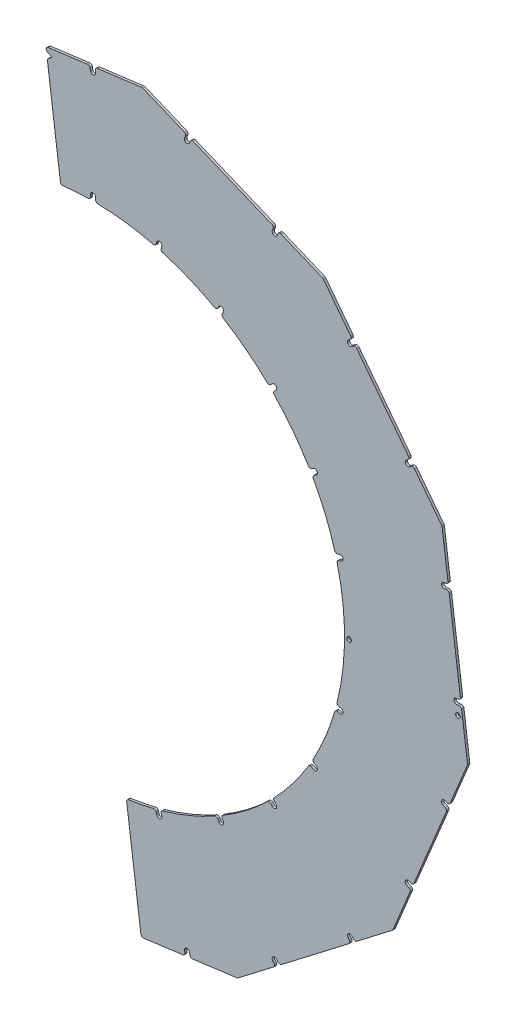
from build123d import *

# Parameters (mm, degrees)
BOSS_EXTRUDE1_DEPTH      = 2
CUT_EXTRUDE1_DEPTH       = 3
CUT_EXTRUDE2_DEPTH       = 3
CIRPATTERN1_COUNT        = 6
CIRPATTERN1_ANGLE        = 150
SKETCH4_R                = 2
BOSS_EXTRUDE3_DEPTH      = 2
FILLET1_R                = 2
F_4_0_4_DIAMETER_HOLE1_D = 4
ALIGNMENT_VEE_CUT_DEPTH  = 3


with BuildPart() as part:
    # Sketch1 → Boss-Extrude1 (new body)
    with BuildSketch(Plane.XY):
        with BuildLine():
            Line((-40.783185859, 313.609700506), (-27.95891263, 216.199674386))
            ThreePointArc((-27.95891263, 216.199674386), (216.134979779, 28.454709904), (28.950357492, -216.069148194))
            Line((28.950357492, -216.069148194), (41.77463072, -313.479174313))
            Line((41.77463072, -313.479174313), (125.292887085, -302.483787269))
            Line((125.292887085, -302.483787269), (259.748716763, -199.312200465))
            Line((259.748716763, -199.312200465), (324.60508755, -42.735070506))
            Line((324.60508755, -42.735070506), (302.483787269, 125.292887085))
            Line((302.483787269, 125.292887085), (199.312200465, 259.748716763))
            Line((199.312200465, 259.748716763), (42.735070506, 324.60508755))
            Line((42.735070506, 324.60508755), (-40.783185859, 313.609700506))
        make_face()
    extrude(amount=BOSS_EXTRUDE1_DEPTH)

    # Sketch2 → Cut-Extrude1 (cut, through all)
    with BuildSketch(Plane.XY.offset(2)):
        with BuildLine():
            Line((-4.728549347, 318.356383452), (3.698731975, 319.465856086))
            ThreePointArc((3.698731975, 319.465856086), (2.373077679, 318.700489221), (1.976894637, 317.221913979))
            Line((1.976894637, 317.221913979), (2.230750938, 315.293683932))
            ThreePointArc((2.230750938, 315.293683932), (0.293683932, 312.769249062), (-2.230750938, 314.706316068))
            Line((-2.230750938, 314.706316068), (-2.48460724, 316.634546114))
            ThreePointArc((-2.48460724, 316.634546114), (-3.249974104, 317.96020041), (-4.728549347, 318.356383452))
        make_face()
        with BuildLine():
            Line((-4.211363636, 217.95931826), (4.211363636, 217.95931826))
            ThreePointArc((4.211363636, 217.95931826), (2.822191762, 218.558458105), (2.25, 219.958945033))
            Line((2.25, 219.958945033), (2.25, 222))
            ThreePointArc((2.25, 222), (0, 224.25), (-2.25, 222))
            Line((-2.25, 222), (-2.25, 219.958945033))
            ThreePointArc((-2.25, 219.958945033), (-2.822191762, 218.558458105), (-4.211363636, 217.95931826))
        make_face()
    cut_extrude1 = extrude(amount=-CUT_EXTRUDE1_DEPTH, mode=Mode.SUBTRACT)

    # Sketch3 → Cut-Extrude2 (cut, through all)
    with BuildSketch(Plane.XY.offset(2)):
        with BuildLine():
            Line((79.111147076, 309.537623289), (86.964123102, 306.284814114))
            ThreePointArc((86.964123102, 306.284814114), (85.433389373, 306.284814114), (84.350997173, 305.202421913))
            Line((84.350997173, 305.202421913), (83.606728155, 303.405597558))
            ThreePointArc((83.606728155, 303.405597558), (80.666961484, 302.187906333), (79.449270259, 305.127673004))
            Line((79.449270259, 305.127673004), (80.193539276, 306.924497359))
            ThreePointArc((80.193539276, 306.924497359), (80.193539276, 308.455231088), (79.111147076, 309.537623289))
        make_face()
        with BuildLine():
            Line((52.344157723, 211.622515703), (60.479887523, 209.442553473))
            ThreePointArc((60.479887523, 209.442553473), (59.293119336, 210.38082226), (59.102897224, 211.881682879))
            Line((59.102897224, 211.881682879), (59.631161122, 213.853190585))
            ThreePointArc((59.631161122, 213.853190585), (58.040170864, 216.608866545), (55.284494904, 215.017876288))
            Line((55.284494904, 215.017876288), (54.756231006, 213.046368582))
            ThreePointArc((54.756231006, 213.046368582), (53.841063516, 211.841696214), (52.344157723, 211.622515703))
        make_face()
    cut_extrude2 = extrude(amount=-CUT_EXTRUDE2_DEPTH, mode=Mode.SUBTRACT)

    # CirPattern1: Cut-Extrude1, Cut-Extrude2 ×6 about axis
    cirpattern1_axis = Axis((0, 0, 0), (0, 0, -1))
    add([cut_extrude1.rotate(cirpattern1_axis, i * CIRPATTERN1_ANGLE / (CIRPATTERN1_COUNT - 1)) for i in range(1, CIRPATTERN1_COUNT)], mode=Mode.SUBTRACT)
    add([cut_extrude2.rotate(cirpattern1_axis, i * CIRPATTERN1_ANGLE / (CIRPATTERN1_COUNT - 1)) for i in range(1, CIRPATTERN1_COUNT)], mode=Mode.SUBTRACT)

    # Sketch4 → Boss-Extrude3 (add, through all)
    with BuildSketch(Plane.XY.offset(2)):
        with BuildLine():
            Line((222, 2.25), (219.958945033, 2.25))
            ThreePointArc((219.958945033, 2.25), (218.558458105, 2.822191762), (217.95931826, 4.211363636))
            ThreePointArc((217.95931826, 4.211363636), (218, 0), (217.95931826, -4.211363636))
            ThreePointArc((217.95931826, -4.211363636), (218.558458105, -2.822191762), (219.958945033, -2.25))
            Line((219.958945033, -2.25), (222, -2.25))
            ThreePointArc((222, -2.25), (224.25, 0), (222, 2.25))
        make_face()
        with Locations((222, 0)):
            Circle(SKETCH4_R, mode=Mode.SUBTRACT)
    extrude(amount=-BOSS_EXTRUDE3_DEPTH)

    # Fillet1
    fillet1_edges = [part.edges().sort_by_distance(p)[0] for p in [
        (-27.95891263, 216.199674386, 1),
        (-40.783185859, 313.609700506, 1),
        (42.735070506, 324.60508755, 1),
        (199.312200465, 259.748716763, 1),
        (302.483787269, 125.292887085, 1),
        (324.60508755, -42.735070506, 1),
        (259.748716763, -199.312200465, 1),
        (125.292887085, -302.483787269, 1),
        (41.77463072, -313.479174313, 1),
        (28.950357492, -216.069148194, 1),
    ]]
    fillet(fillet1_edges, radius=FILLET1_R)

    # 4.0 _4_ Diameter Hole1 (through all)
    with Locations(Plane.XY.offset(2)):
        with Locations((316.305261922, -9.914448614)):
            Hole(F_4_0_4_DIAMETER_HOLE1_D / 2)

    # Sketch9 → alignment_vee cut (cut, through all)
    with BuildSketch(Plane.XY.offset(2)):
        with BuildLine():
            Line((-40.452184699, 311.095497083), (-39.547872712, 304.226565592))
            ThreePointArc((-39.547872712, 304.226565592), (-39.480307383, 304.739775216), (-39.16518928, 305.150445124))
            Line((-39.16518928, 305.150445124), (-36.416932692, 307.259256574))
            ThreePointArc((-36.416932692, 307.259256574), (-36.03424926, 308.183136106), (-36.643010689, 308.976489447))
            Line((-36.643010689, 308.976489447), (-39.84342327, 310.302143743))
            ThreePointArc((-39.84342327, 310.302143743), (-40.254093178, 310.617261846), (-40.452184699, 311.095497083))
        make_face()
    extrude(amount=-ALIGNMENT_VEE_CUT_DEPTH, mode=Mode.SUBTRACT)


solid = part.part
